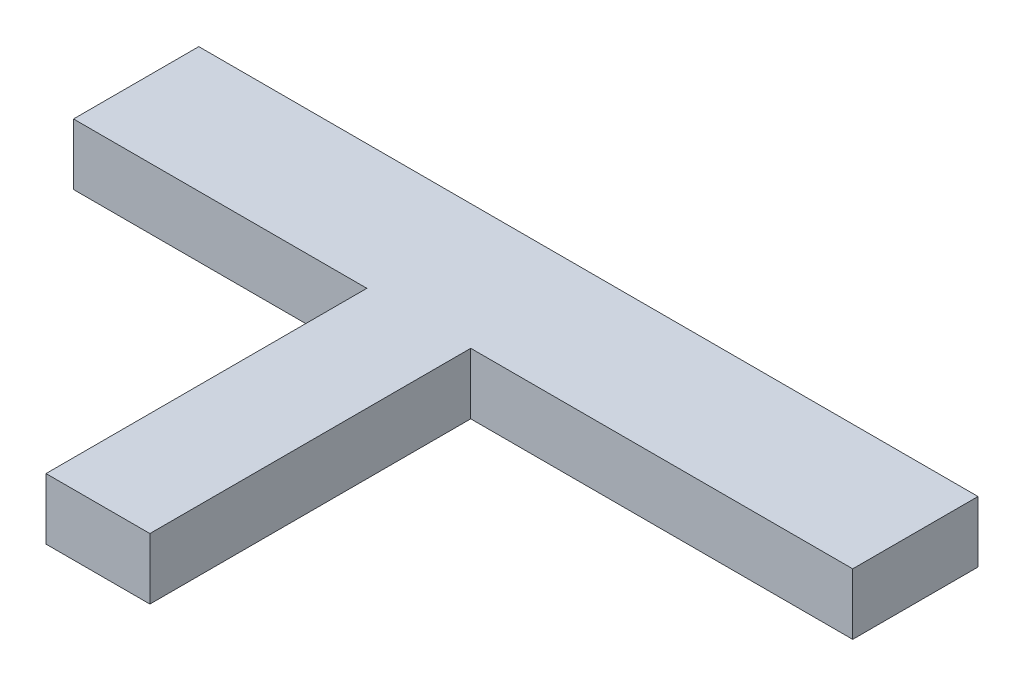
from build123d import *

# Parameters (mm, degrees)
SKETCH2_W           = 323.85
SKETCH2_H           = 185.42
BOSS_EXTRUDE1_DEPTH = 25.4
SKETCH3_W           = 158.75
SKETCH3_H           = 133.35
CUT_EXTRUDE2_DEPTH  = 25.4


with BuildPart() as part:
    # Sketch2 → Boss-Extrude1 (new body)
    with BuildSketch(Plane(origin=(0, 0, 0), x_dir=(1, 0, 0), z_dir=(0, 1, 0))):
        with Locations((8.034446565, -16.382757634)):
            Rectangle(SKETCH2_W, SKETCH2_H)
    extrude(amount=BOSS_EXTRUDE1_DEPTH)

    # Sketch3 → Cut-Extrude2 (cut)
    with BuildSketch(Plane(origin=(0, 25.4, 0), x_dir=(1, 0, 0), z_dir=(0, 1, 0))):
        Polygon((-153.890553435, 24.257242366), (-153.890553435, -12.50606057), (-153.890553435, -109.092757634), (-31.970553435, -109.092757634), (-31.970553435, 24.257242366), align=None)
        with Locations((90.584446565, -42.417757634)):
            Rectangle(SKETCH3_W, SKETCH3_H)
    extrude(amount=-CUT_EXTRUDE2_DEPTH, mode=Mode.SUBTRACT)


solid = part.part
